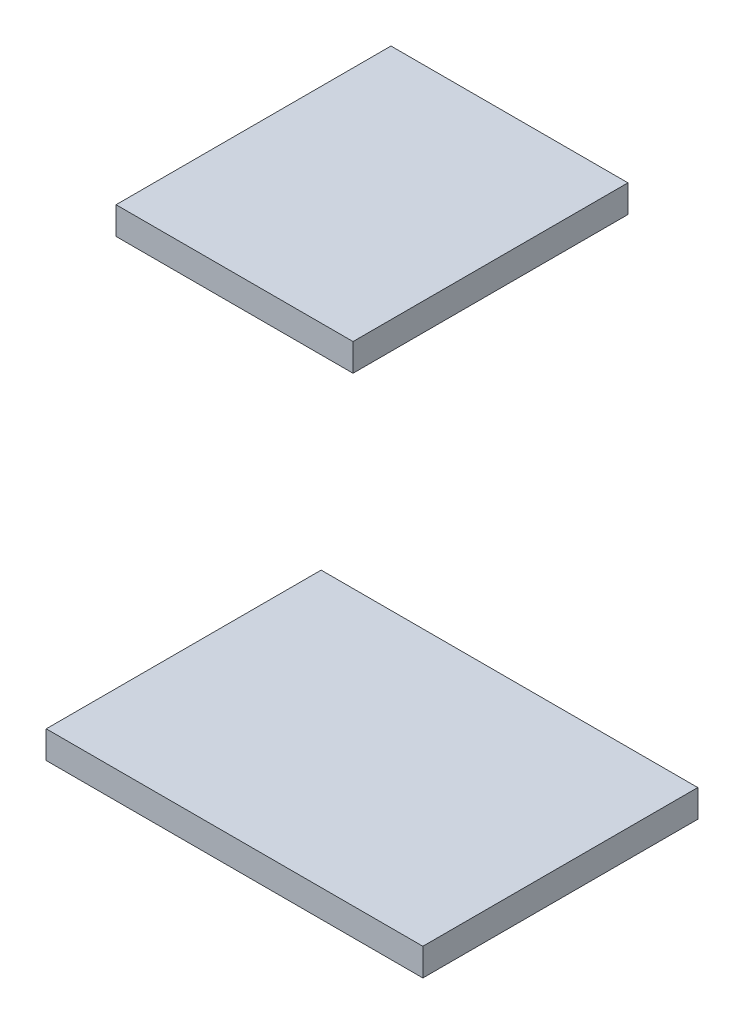
from build123d import *

# Parameters (mm, degrees)
SKIZZE1_W                         = 8.62
SKIZZE1_H                         = 1
AUFSATZ_LINEAR_AUSTRAGEN1_DEPTH   = 10
SKIZZE1_W_2                       = 13.7
AUFSATZ_LINEAR_AUSTRAGEN1_2_DEPTH = 10


with BuildPart() as part:
    # Skizze1 → Aufsatz-Linear austragen1 (new body)
    with BuildSketch(Plane.XY):
        with Locations((138.14, -33.08)):
            Rectangle(SKIZZE1_W, SKIZZE1_H)
    extrude(amount=AUFSATZ_LINEAR_AUSTRAGEN1_DEPTH)


with BuildPart() as body_2:
    # Skizze1 → Aufsatz-Linear austragen1 2 (new body)
    with BuildSketch(Plane.XY):
        with Locations((138.14, -50.86)):
            Rectangle(SKIZZE1_W_2, SKIZZE1_H)
    extrude(amount=AUFSATZ_LINEAR_AUSTRAGEN1_2_DEPTH)


solid = Compound([part.part, body_2.part])
